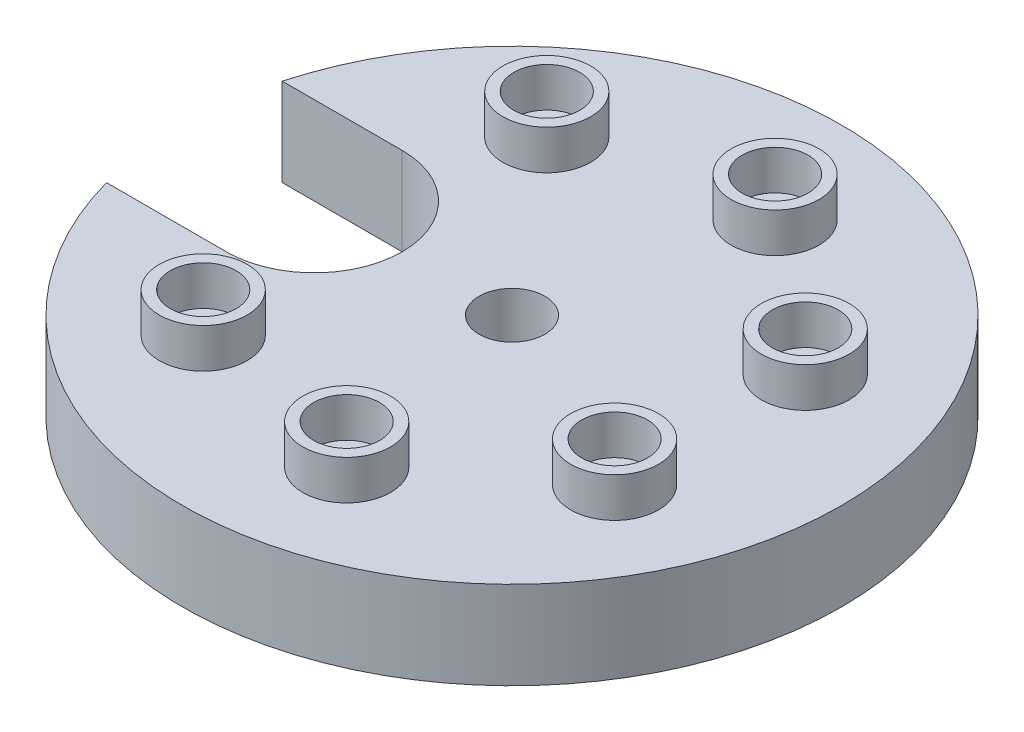
from build123d import *

# Parameters (mm, degrees)
SKETCH1_R           = 75
BOSS_EXTRUDE1_DEPTH = 20
SKETCH2_R           = 10
SKETCH2_R_2         = 7.5
BOSS_EXTRUDE2_DEPTH = 9
SKETCH3_R           = 7.5
CUT_EXTRUDE1_DEPTH  = 20
SKETCH4_R           = 15.621868033
CUT_EXTRUDE2_DEPTH  = 60


with BuildPart() as part:
    # Sketch1 → Boss-Extrude1 (new body)
    with BuildSketch(Plane(origin=(0, 0, 0), x_dir=(1, 0, 0), z_dir=(0, 1, 0))):
        Circle(SKETCH1_R)
    extrude(amount=BOSS_EXTRUDE1_DEPTH)

    # Sketch2 → Boss-Extrude2 (add)
    with BuildSketch(Plane(origin=(0, 20, 0), x_dir=(1, 0, 0), z_dir=(0, 1, 0))):
        with Locations((-50, 0)):
            Circle(SKETCH2_R)
        with Locations((-50, 0)):
            Circle(SKETCH2_R_2, mode=Mode.SUBTRACT)
        with Locations((-31.174490093, 39.091574123)):
            Circle(SKETCH2_R)
        with Locations((-31.174490093, 39.091574123)):
            Circle(SKETCH2_R_2, mode=Mode.SUBTRACT)
        with Locations((11.126046698, 48.746395609)):
            Circle(SKETCH2_R)
        with Locations((11.126046698, 48.746395609)):
            Circle(SKETCH2_R_2, mode=Mode.SUBTRACT)
        with Locations((45.048443395, 21.694186956)):
            Circle(SKETCH2_R)
        with Locations((45.048443395, 21.694186956)):
            Circle(SKETCH2_R_2, mode=Mode.SUBTRACT)
        with Locations((45.048443395, -21.694186956)):
            Circle(SKETCH2_R)
        with Locations((45.048443395, -21.694186956)):
            Circle(SKETCH2_R_2, mode=Mode.SUBTRACT)
        with Locations((11.126046698, -48.746395609)):
            Circle(SKETCH2_R)
        with Locations((11.126046698, -48.746395609)):
            Circle(SKETCH2_R_2, mode=Mode.SUBTRACT)
        with Locations((-31.174490093, -39.091574123)):
            Circle(SKETCH2_R)
        with Locations((-31.174490093, -39.091574123)):
            Circle(SKETCH2_R_2, mode=Mode.SUBTRACT)
    extrude(amount=BOSS_EXTRUDE2_DEPTH)

    # Sketch3 → Cut-Extrude1 (cut)
    with BuildSketch(Plane(origin=(0, 20, 0), x_dir=(1, 0, 0), z_dir=(0, 1, 0))):
        Circle(SKETCH3_R)
        with BuildLine():
            Line((-96.640436965, 20), (-45, 20))
            ThreePointArc((-45, 20), (-25, 0), (-45, -20))
            Line((-45, -20), (-96.640436965, -20))
            Line((-96.640436965, -20), (-96.640436965, 20))
        make_face()
    extrude(amount=-CUT_EXTRUDE1_DEPTH, mode=Mode.SUBTRACT)

    # Sketch4 → Cut-Extrude2 (cut)
    with BuildSketch(Plane(origin=(0, 0, 0), x_dir=(1, 0, 0), z_dir=(0, 1, 0))):
        with Locations((-50, 0)):
            Circle(SKETCH4_R)
    extrude(amount=CUT_EXTRUDE2_DEPTH, mode=Mode.SUBTRACT)


solid = part.part
